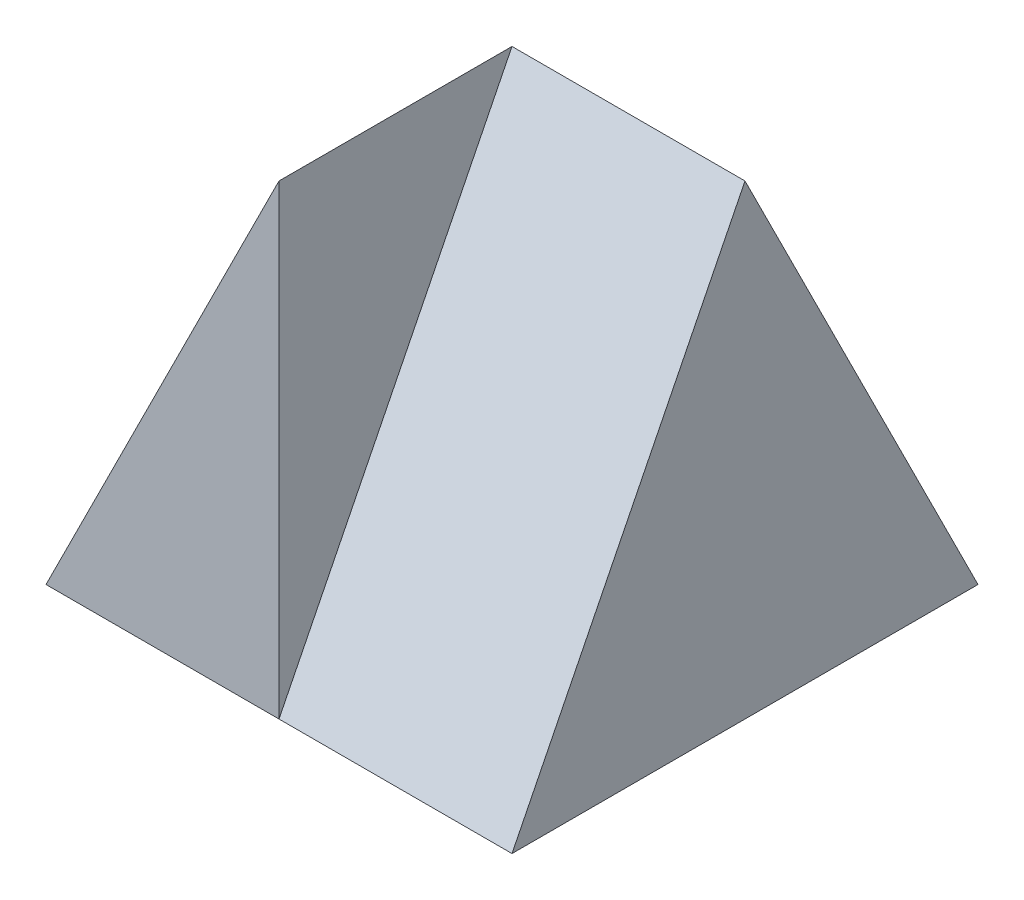
from build123d import *

# Parameters (mm, degrees)
SKETCH1_W           = 40
SKETCH1_H           = 40
BOSS_EXTRUDE1_DEPTH = 40
CUT_EXTRUDE1_DEPTH  = 40
CUT_EXTRUDE2_DEPTH  = 40
CUT_EXTRUDE5_DEPTH  = 20
CUT_EXTRUDE6_DEPTH  = 20
CUT_EXTRUDE7_DEPTH  = 20
CUT_EXTRUDE8_DEPTH  = 20
CUT_EXTRUDE9_DEPTH  = 20
CUT_EXTRUDE10_DEPTH = 20
CUT_EXTRUDE11_DEPTH = 20
CUT_EXTRUDE12_DEPTH = 20
CUT_EXTRUDE17_DEPTH = 20
CUT_EXTRUDE18_DEPTH = 7
SKETCH20_W          = 20
SKETCH20_H          = 44.72135955
BOSS_EXTRUDE6_DEPTH = 7
CUT_EXTRUDE20_DEPTH = 20
BOSS_EXTRUDE7_DEPTH = 2
SKETCH23_W          = 20
SKETCH23_H          = 44.72135955
CUT_EXTRUDE21_DEPTH = 2
SKETCH24_W          = 40
SKETCH24_H          = 40
CUT_EXTRUDE22_DEPTH = 20
BOSS_EXTRUDE8_DEPTH = 5
SKETCH26_W          = 20
SKETCH26_H          = 44.72135955
CUT_EXTRUDE23_DEPTH = 5
SKETCH27_W          = 40
SKETCH27_H          = 40
CUT_EXTRUDE24_DEPTH = 5


with BuildPart() as part:
    # Sketch1 → Boss-Extrude1 (new body)
    with BuildSketch(Plane.XY):
        with Locations((20, 20)):
            Rectangle(SKETCH1_W, SKETCH1_H)
    extrude(amount=BOSS_EXTRUDE1_DEPTH)

    # Sketch2 → Cut-Extrude1 (cut)
    with BuildSketch(Plane.XY.offset(40)):
        Polygon((0, 0), (20, 40), (0, 40), align=None)
    extrude(amount=-CUT_EXTRUDE1_DEPTH, mode=Mode.SUBTRACT)

    # Sketch3 → Cut-Extrude2 (cut)
    with BuildSketch(Plane.XZ):
        Polygon((0, 20), (20, 0), (0, 0), align=None)
    extrude(amount=-CUT_EXTRUDE2_DEPTH, mode=Mode.SUBTRACT)

    # Sketch5 → Cut-Extrude5 (cut)
    with BuildSketch(Plane(origin=(40, 0, 0), x_dir=(0, 0, -1), z_dir=(1, 0, 0))):
        Polygon((-40, 40), (-40, 0), (-20, 40), align=None)
        Polygon((0, 40), (-20, 40), (0, 0), align=None)
    extrude(amount=-CUT_EXTRUDE5_DEPTH, mode=Mode.SUBTRACT)

    # Sketch6 → Cut-Extrude6 (cut)
    with BuildSketch(Plane(origin=(8.888888889, -4.444444444, 8.888888889), x_dir=(-0.745355992, -0.298142397, 0.596284794), z_dir=(-0.666666667, 0.333333333, -0.666666667))):
        Polygon((11.92569588, 8.94427191), (-14.90711985, 0), (-14.90711985, 44.72135955), align=None)
    extrude(amount=CUT_EXTRUDE6_DEPTH, mode=Mode.SUBTRACT)

    # Sketch7 → Cut-Extrude7 (cut)
    with BuildSketch(Plane(origin=(11.111111111, 4.444444444, -8.888888889), x_dir=(0.553636532, 0.221454613, 0.802772972), z_dir=(-0.745355992, -0.298142397, 0.596284794))):
        Polygon((11.072730647, -7.427813527), (35.986374603, 29.711254108), (18.738467249, 20.569329767), align=None)
    extrude(amount=-CUT_EXTRUDE7_DEPTH, mode=Mode.SUBTRACT)

    # Sketch8 → Cut-Extrude8 (cut)
    with BuildSketch(Plane(origin=(-5.521048999, 6.735679779, -3.53347136), x_dir=(0.809280197, 0.520190643, -0.272886895), z_dir=(0.587422814, -0.716655833, 0.375950601))):
        Polygon((31.535491772, 36.292919071), (23.931393494, 18.313965316), (31.535491772, 15.097854334), align=None)
    extrude(amount=-CUT_EXTRUDE8_DEPTH, mode=Mode.SUBTRACT)

    # Sketch9 → Cut-Extrude9 (cut)
    with BuildSketch(Plane(origin=(20, 0, 0), x_dir=(0, 0, -1), z_dir=(1, 0, 0))):
        Polygon((-20, 40), (0, 40), (0, 0), (-1.230769231, 30.153846154), align=None)
    extrude(amount=-CUT_EXTRUDE9_DEPTH, mode=Mode.SUBTRACT)

    # Sketch10 → Cut-Extrude10 (cut)
    with BuildSketch(Plane(origin=(7.990012484, -0.399500624, 9.787765293), x_dir=(0.774918948, 0.02577693, -0.631534777), z_dir=(0.632060618, -0.031603031, 0.774274256))):
        Polygon((15.498378958, 30.178953441), (7.557101782, 27.920237591), (15.498378958, 0), align=None)
    extrude(amount=-CUT_EXTRUDE10_DEPTH, mode=Mode.SUBTRACT)

    # Sketch11 → Cut-Extrude11 (cut)
    with BuildSketch(Plane(origin=(8.256091734, 16.512183469, 18.576206402), x_dir=(0.9490106, -0.209436822, -0.235616425), z_dir=(0.315244162, 0.630488325, 0.709299366))):
        Polygon((10.513930203, 21.573833283), (12.374896836, 21.719587039), (5.890410618, 16.609095971), align=None)
    extrude(amount=-CUT_EXTRUDE11_DEPTH, mode=Mode.SUBTRACT)

    # Sketch12 → Cut-Extrude12 (cut)
    with BuildSketch(Plane(origin=(10, 0, 10), x_dir=(-0.707106781, 0, 0.707106781), z_dir=(-0.707106781, 0, -0.707106781))):
        Polygon((-12.408696288, 30.030304373), (-12.401565085, 30.153846154), (-11.644525493, 30.434663376), align=None)
    extrude(amount=-CUT_EXTRUDE12_DEPTH, mode=Mode.SUBTRACT)

    # Sketch15 → Cut-Extrude17 (cut)
    with BuildSketch(Plane(origin=(0, 23.140147524, -12.139093783), x_dir=(1, 0, 0), z_dir=(0, 0.885547225, -0.464549364))):
        Polygon((18.23392294, -15.702348159), (20, -15.097854334), (18.769230769, -15.097854334), align=None)
    extrude(amount=-CUT_EXTRUDE17_DEPTH, mode=Mode.SUBTRACT)

    # Sketch16 → Cut-Extrude18 (cut)
    with BuildSketch(Plane(origin=(0, 0, 0), x_dir=(-1, 0, 0), z_dir=(0, 0.04078237, -0.999168053))):
        Polygon((-18.774273291, 30.055308794), (-18.769230769, 30.178953441), (-20, 30.178953441), align=None)
    extrude(amount=-CUT_EXTRUDE18_DEPTH, mode=Mode.SUBTRACT)

    # Sketch20 → Boss-Extrude6 (add)
    with BuildSketch(Plane(origin=(0, 0, 0), x_dir=(-1, 0, 0), z_dir=(0, 0.447213595, -0.894427191))):
        with Locations((-30, 22.360679775)):
            Rectangle(SKETCH20_W, SKETCH20_H)
    extrude(amount=-BOSS_EXTRUDE6_DEPTH)

    # Sketch21 → Cut-Extrude20 (cut)
    with BuildSketch(Plane(origin=(40, 0, 0), x_dir=(0, 0, -1), z_dir=(1, 0, 0))):
        Polygon((-7.826237921, 0), (0, 0), (-6.260990337, -3.130495168), align=None)
        Polygon((-23.913118961, 32.173762079), (-20, 40), (-26.260990337, 36.869504832), align=None)
    extrude(amount=-CUT_EXTRUDE20_DEPTH, mode=Mode.SUBTRACT)

    # Sketch22 → Boss-Extrude7 (add)
    with BuildSketch(Plane(origin=(8.888888889, -4.444444444, 8.888888889), x_dir=(-0.596284794, 0.298142397, 0.745355992), z_dir=(-0.666666667, 0.333333333, -0.666666667))):
        Polygon((14.90711985, 44.72135955), (-11.92569588, 8.94427191), (14.90711985, 0), align=None)
    extrude(amount=-BOSS_EXTRUDE7_DEPTH)

    # Sketch23 → Cut-Extrude21 (cut)
    with BuildSketch(Plane(origin=(0, 16, 32), x_dir=(1, 0, 0), z_dir=(0, 0.447213595, 0.894427191))):
        with Locations((30, 4.472135955)):
            Rectangle(SKETCH23_W, SKETCH23_H)
    extrude(amount=CUT_EXTRUDE21_DEPTH, mode=Mode.SUBTRACT)

    # Sketch24 → Cut-Extrude22 (cut)
    with BuildSketch(Plane.XZ):
        with Locations((20, 20)):
            Rectangle(SKETCH24_W, SKETCH24_H)
    extrude(amount=CUT_EXTRUDE22_DEPTH, mode=Mode.SUBTRACT)

    # Sketch25 → Boss-Extrude8 (add)
    with BuildSketch(Plane(origin=(8.888888889, -4.444444444, 8.888888889), x_dir=(-0.596284794, 0.298142397, 0.745355992), z_dir=(-0.666666667, 0.333333333, -0.666666667))):
        Polygon((14.90711985, 0), (14.90711985, 44.72135955), (-11.92569588, 8.94427191), align=None)
    extrude(amount=-BOSS_EXTRUDE8_DEPTH)

    # Sketch26 → Cut-Extrude23 (cut)
    with BuildSketch(Plane(origin=(0, 16, 32), x_dir=(1, 0, 0), z_dir=(0, 0.447213595, 0.894427191))):
        with Locations((30, 4.472135955)):
            Rectangle(SKETCH26_W, SKETCH26_H)
    extrude(amount=CUT_EXTRUDE23_DEPTH, mode=Mode.SUBTRACT)

    # Sketch27 → Cut-Extrude24 (cut)
    with BuildSketch(Plane.XZ):
        with Locations((20, 20)):
            Rectangle(SKETCH27_W, SKETCH27_H)
    extrude(amount=CUT_EXTRUDE24_DEPTH, mode=Mode.SUBTRACT)


solid = part.part
